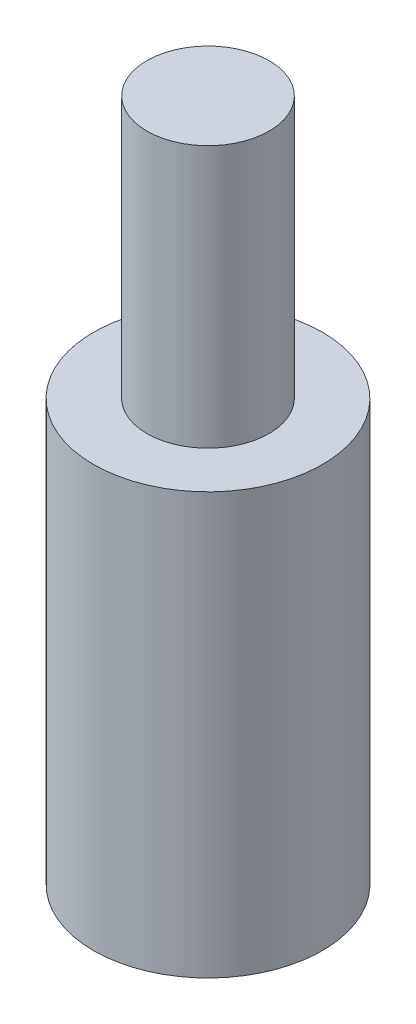
from build123d import *


with BuildPart() as part:
    # Эскиз1 → Повернуть1 (revolve)
    with BuildSketch(Plane.XY):
        Polygon((0, 0), (-7.5, 0), (-7.5, 27.578467153), (-4, 27.578467153), (-4, 44.738402271), (0, 44.738402271), align=None)
    revolve(axis=Axis((0, 55.944890511, 0), (0, -1, 0)))


solid = part.part
